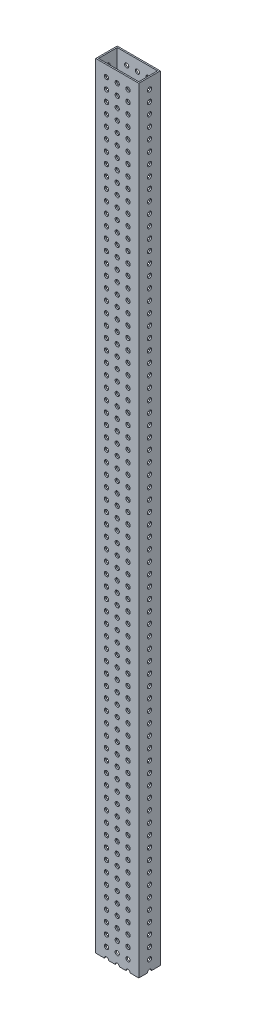
from build123d import *

# Parameters (mm, degrees)
SKETCH1_W           = 50.8
SKETCH1_H           = 25.4
SKETCH1_W_2         = 47.625
SKETCH1_H_2         = 22.225
BOSS_EXTRUDE1_DEPTH = 914.4
SKETCH3_R           = 2.4892
CUT_EXTRUDE1_DEPTH  = 51.8
SKETCH4_R           = 2.4892
CUT_EXTRUDE2_DEPTH  = 26.4


with BuildPart() as part:
    # Sketch1 → Boss-Extrude1 (new body)
    with BuildSketch(Plane(origin=(0, 0, 0), x_dir=(1, 0, 0), z_dir=(0, 1, 0))):
        with Locations((25.4, 12.7)):
            Rectangle(SKETCH1_W, SKETCH1_H)
        with Locations((25.4, 12.7)):
            Rectangle(SKETCH1_W_2, SKETCH1_H_2, mode=Mode.SUBTRACT)
    extrude(amount=BOSS_EXTRUDE1_DEPTH)

    # Sketch3 → Cut-Extrude1 (cut, through all)
    with BuildSketch(Plane(origin=(50.8, 0, 0), x_dir=(0, 0, -1), z_dir=(1, 0, 0))):
        with Locations((12.7, 901.7)):
            Circle(SKETCH3_R)
        with Locations((12.7, 889)):
            Circle(SKETCH3_R)
        with Locations((12.7, 876.3)):
            Circle(SKETCH3_R)
        with Locations((12.7, 863.6)):
            Circle(SKETCH3_R)
        with Locations((12.7, 850.9)):
            Circle(SKETCH3_R)
        with Locations((12.7, 838.2)):
            Circle(SKETCH3_R)
        with Locations((12.7, 825.5)):
            Circle(SKETCH3_R)
        with Locations((12.7, 812.8)):
            Circle(SKETCH3_R)
        with Locations((12.7, 800.1)):
            Circle(SKETCH3_R)
        with Locations((12.7, 787.4)):
            Circle(SKETCH3_R)
        with Locations((12.7, 774.7)):
            Circle(SKETCH3_R)
        with Locations((12.7, 762)):
            Circle(SKETCH3_R)
        with Locations((12.7, 749.3)):
            Circle(SKETCH3_R)
        with Locations((12.7, 736.6)):
            Circle(SKETCH3_R)
        with Locations((12.7, 723.9)):
            Circle(SKETCH3_R)
        with Locations((12.7, 711.2)):
            Circle(SKETCH3_R)
        with Locations((12.7, 698.5)):
            Circle(SKETCH3_R)
        with Locations((12.7, 685.8)):
            Circle(SKETCH3_R)
        with Locations((12.7, 673.1)):
            Circle(SKETCH3_R)
        with Locations((12.7, 660.4)):
            Circle(SKETCH3_R)
        with Locations((12.7, 647.7)):
            Circle(SKETCH3_R)
        with Locations((12.7, 635)):
            Circle(SKETCH3_R)
        with Locations((12.7, 622.3)):
            Circle(SKETCH3_R)
        with Locations((12.7, 609.6)):
            Circle(SKETCH3_R)
        with Locations((12.7, 596.9)):
            Circle(SKETCH3_R)
        with Locations((12.7, 584.2)):
            Circle(SKETCH3_R)
        with Locations((12.7, 571.5)):
            Circle(SKETCH3_R)
        with Locations((12.7, 558.8)):
            Circle(SKETCH3_R)
        with Locations((12.7, 546.1)):
            Circle(SKETCH3_R)
        with Locations((12.7, 533.4)):
            Circle(SKETCH3_R)
        with Locations((12.7, 520.7)):
            Circle(SKETCH3_R)
        with Locations((12.7, 508)):
            Circle(SKETCH3_R)
        with Locations((12.7, 495.3)):
            Circle(SKETCH3_R)
        with Locations((12.7, 482.6)):
            Circle(SKETCH3_R)
        with Locations((12.7, 469.9)):
            Circle(SKETCH3_R)
        with Locations((12.7, 457.2)):
            Circle(SKETCH3_R)
        with Locations((12.7, 444.5)):
            Circle(SKETCH3_R)
        with Locations((12.7, 431.8)):
            Circle(SKETCH3_R)
        with Locations((12.7, 419.1)):
            Circle(SKETCH3_R)
        with Locations((12.7, 406.4)):
            Circle(SKETCH3_R)
        with Locations((12.7, 393.7)):
            Circle(SKETCH3_R)
        with Locations((12.7, 381)):
            Circle(SKETCH3_R)
        with Locations((12.7, 368.3)):
            Circle(SKETCH3_R)
        with Locations((12.7, 355.6)):
            Circle(SKETCH3_R)
        with Locations((12.7, 342.9)):
            Circle(SKETCH3_R)
        with Locations((12.7, 330.2)):
            Circle(SKETCH3_R)
        with Locations((12.7, 317.5)):
            Circle(SKETCH3_R)
        with Locations((12.7, 304.8)):
            Circle(SKETCH3_R)
        with Locations((12.7, 292.1)):
            Circle(SKETCH3_R)
        with Locations((12.7, 279.4)):
            Circle(SKETCH3_R)
        with Locations((12.7, 266.7)):
            Circle(SKETCH3_R)
        with Locations((12.7, 254)):
            Circle(SKETCH3_R)
        with Locations((12.7, 241.3)):
            Circle(SKETCH3_R)
        with Locations((12.7, 228.6)):
            Circle(SKETCH3_R)
        with Locations((12.7, 215.9)):
            Circle(SKETCH3_R)
        with Locations((12.7, 203.2)):
            Circle(SKETCH3_R)
        with Locations((12.7, 190.5)):
            Circle(SKETCH3_R)
        with Locations((12.7, 177.8)):
            Circle(SKETCH3_R)
        with Locations((12.7, 165.1)):
            Circle(SKETCH3_R)
        with Locations((12.7, 152.4)):
            Circle(SKETCH3_R)
        with Locations((12.7, 139.7)):
            Circle(SKETCH3_R)
        with Locations((12.7, 127)):
            Circle(SKETCH3_R)
        with Locations((12.7, 114.3)):
            Circle(SKETCH3_R)
        with Locations((12.7, 101.6)):
            Circle(SKETCH3_R)
        with Locations((12.7, 88.9)):
            Circle(SKETCH3_R)
        with Locations((12.7, 76.2)):
            Circle(SKETCH3_R)
        with Locations((12.7, 63.5)):
            Circle(SKETCH3_R)
        with Locations((12.7, 50.8)):
            Circle(SKETCH3_R)
        with Locations((12.7, 38.1)):
            Circle(SKETCH3_R)
        with Locations((12.7, 25.4)):
            Circle(SKETCH3_R)
        with Locations((12.7, 12.7)):
            Circle(SKETCH3_R)
        with Locations((12.7, 0)):
            Circle(SKETCH3_R)
    extrude(amount=-CUT_EXTRUDE1_DEPTH, mode=Mode.SUBTRACT)

    # Sketch4 → Cut-Extrude2 (cut, through all)
    with BuildSketch(Plane.XY):
        with Locations((12.7, 901.7)):
            Circle(SKETCH4_R)
        with Locations((25.4, 901.7)):
            Circle(SKETCH4_R)
        with Locations((38.1, 901.7)):
            Circle(SKETCH4_R)
        with Locations((25.4, 889)):
            Circle(SKETCH4_R)
        with Locations((38.1, 889)):
            Circle(SKETCH4_R)
        with Locations((25.4, 876.3)):
            Circle(SKETCH4_R)
        with Locations((38.1, 876.3)):
            Circle(SKETCH4_R)
        with Locations((25.4, 863.6)):
            Circle(SKETCH4_R)
        with Locations((38.1, 863.6)):
            Circle(SKETCH4_R)
        with Locations((25.4, 850.9)):
            Circle(SKETCH4_R)
        with Locations((38.1, 850.9)):
            Circle(SKETCH4_R)
        with Locations((25.4, 838.2)):
            Circle(SKETCH4_R)
        with Locations((38.1, 838.2)):
            Circle(SKETCH4_R)
        with Locations((25.4, 825.5)):
            Circle(SKETCH4_R)
        with Locations((38.1, 825.5)):
            Circle(SKETCH4_R)
        with Locations((25.4, 812.8)):
            Circle(SKETCH4_R)
        with Locations((38.1, 812.8)):
            Circle(SKETCH4_R)
        with Locations((25.4, 800.1)):
            Circle(SKETCH4_R)
        with Locations((38.1, 800.1)):
            Circle(SKETCH4_R)
        with Locations((25.4, 787.4)):
            Circle(SKETCH4_R)
        with Locations((38.1, 787.4)):
            Circle(SKETCH4_R)
        with Locations((25.4, 774.7)):
            Circle(SKETCH4_R)
        with Locations((38.1, 774.7)):
            Circle(SKETCH4_R)
        with Locations((25.4, 762)):
            Circle(SKETCH4_R)
        with Locations((38.1, 762)):
            Circle(SKETCH4_R)
        with Locations((25.4, 749.3)):
            Circle(SKETCH4_R)
        with Locations((38.1, 749.3)):
            Circle(SKETCH4_R)
        with Locations((25.4, 736.6)):
            Circle(SKETCH4_R)
        with Locations((38.1, 736.6)):
            Circle(SKETCH4_R)
        with Locations((25.4, 723.9)):
            Circle(SKETCH4_R)
        with Locations((38.1, 723.9)):
            Circle(SKETCH4_R)
        with Locations((25.4, 711.2)):
            Circle(SKETCH4_R)
        with Locations((38.1, 711.2)):
            Circle(SKETCH4_R)
        with Locations((25.4, 698.5)):
            Circle(SKETCH4_R)
        with Locations((38.1, 698.5)):
            Circle(SKETCH4_R)
        with Locations((25.4, 685.8)):
            Circle(SKETCH4_R)
        with Locations((38.1, 685.8)):
            Circle(SKETCH4_R)
        with Locations((25.4, 673.1)):
            Circle(SKETCH4_R)
        with Locations((38.1, 673.1)):
            Circle(SKETCH4_R)
        with Locations((25.4, 660.4)):
            Circle(SKETCH4_R)
        with Locations((38.1, 660.4)):
            Circle(SKETCH4_R)
        with Locations((25.4, 647.7)):
            Circle(SKETCH4_R)
        with Locations((38.1, 647.7)):
            Circle(SKETCH4_R)
        with Locations((25.4, 635)):
            Circle(SKETCH4_R)
        with Locations((38.1, 635)):
            Circle(SKETCH4_R)
        with Locations((25.4, 622.3)):
            Circle(SKETCH4_R)
        with Locations((38.1, 622.3)):
            Circle(SKETCH4_R)
        with Locations((25.4, 609.6)):
            Circle(SKETCH4_R)
        with Locations((38.1, 609.6)):
            Circle(SKETCH4_R)
        with Locations((25.4, 596.9)):
            Circle(SKETCH4_R)
        with Locations((38.1, 596.9)):
            Circle(SKETCH4_R)
        with Locations((25.4, 584.2)):
            Circle(SKETCH4_R)
        with Locations((38.1, 584.2)):
            Circle(SKETCH4_R)
        with Locations((25.4, 571.5)):
            Circle(SKETCH4_R)
        with Locations((38.1, 571.5)):
            Circle(SKETCH4_R)
        with Locations((25.4, 558.8)):
            Circle(SKETCH4_R)
        with Locations((38.1, 558.8)):
            Circle(SKETCH4_R)
        with Locations((25.4, 546.1)):
            Circle(SKETCH4_R)
        with Locations((38.1, 546.1)):
            Circle(SKETCH4_R)
        with Locations((25.4, 533.4)):
            Circle(SKETCH4_R)
        with Locations((38.1, 533.4)):
            Circle(SKETCH4_R)
        with Locations((25.4, 520.7)):
            Circle(SKETCH4_R)
        with Locations((38.1, 520.7)):
            Circle(SKETCH4_R)
        with Locations((25.4, 508)):
            Circle(SKETCH4_R)
        with Locations((38.1, 508)):
            Circle(SKETCH4_R)
        with Locations((25.4, 495.3)):
            Circle(SKETCH4_R)
        with Locations((38.1, 495.3)):
            Circle(SKETCH4_R)
        with Locations((25.4, 482.6)):
            Circle(SKETCH4_R)
        with Locations((38.1, 482.6)):
            Circle(SKETCH4_R)
        with Locations((25.4, 469.9)):
            Circle(SKETCH4_R)
        with Locations((38.1, 469.9)):
            Circle(SKETCH4_R)
        with Locations((25.4, 457.2)):
            Circle(SKETCH4_R)
        with Locations((38.1, 457.2)):
            Circle(SKETCH4_R)
        with Locations((25.4, 444.5)):
            Circle(SKETCH4_R)
        with Locations((38.1, 444.5)):
            Circle(SKETCH4_R)
        with Locations((25.4, 431.8)):
            Circle(SKETCH4_R)
        with Locations((38.1, 431.8)):
            Circle(SKETCH4_R)
        with Locations((25.4, 419.1)):
            Circle(SKETCH4_R)
        with Locations((38.1, 419.1)):
            Circle(SKETCH4_R)
        with Locations((25.4, 406.4)):
            Circle(SKETCH4_R)
        with Locations((38.1, 406.4)):
            Circle(SKETCH4_R)
        with Locations((25.4, 393.7)):
            Circle(SKETCH4_R)
        with Locations((38.1, 393.7)):
            Circle(SKETCH4_R)
        with Locations((25.4, 381)):
            Circle(SKETCH4_R)
        with Locations((38.1, 381)):
            Circle(SKETCH4_R)
        with Locations((25.4, 368.3)):
            Circle(SKETCH4_R)
        with Locations((38.1, 368.3)):
            Circle(SKETCH4_R)
        with Locations((25.4, 355.6)):
            Circle(SKETCH4_R)
        with Locations((38.1, 355.6)):
            Circle(SKETCH4_R)
        with Locations((25.4, 342.9)):
            Circle(SKETCH4_R)
        with Locations((38.1, 342.9)):
            Circle(SKETCH4_R)
        with Locations((25.4, 330.2)):
            Circle(SKETCH4_R)
        with Locations((38.1, 330.2)):
            Circle(SKETCH4_R)
        with Locations((25.4, 317.5)):
            Circle(SKETCH4_R)
        with Locations((38.1, 317.5)):
            Circle(SKETCH4_R)
        with Locations((25.4, 304.8)):
            Circle(SKETCH4_R)
        with Locations((38.1, 304.8)):
            Circle(SKETCH4_R)
        with Locations((25.4, 292.1)):
            Circle(SKETCH4_R)
        with Locations((38.1, 292.1)):
            Circle(SKETCH4_R)
        with Locations((25.4, 279.4)):
            Circle(SKETCH4_R)
        with Locations((38.1, 279.4)):
            Circle(SKETCH4_R)
        with Locations((25.4, 266.7)):
            Circle(SKETCH4_R)
        with Locations((38.1, 266.7)):
            Circle(SKETCH4_R)
        with Locations((25.4, 254)):
            Circle(SKETCH4_R)
        with Locations((38.1, 254)):
            Circle(SKETCH4_R)
        with Locations((25.4, 241.3)):
            Circle(SKETCH4_R)
        with Locations((38.1, 241.3)):
            Circle(SKETCH4_R)
        with Locations((25.4, 228.6)):
            Circle(SKETCH4_R)
        with Locations((38.1, 228.6)):
            Circle(SKETCH4_R)
        with Locations((25.4, 215.9)):
            Circle(SKETCH4_R)
        with Locations((38.1, 215.9)):
            Circle(SKETCH4_R)
        with Locations((25.4, 203.2)):
            Circle(SKETCH4_R)
        with Locations((38.1, 203.2)):
            Circle(SKETCH4_R)
        with Locations((25.4, 190.5)):
            Circle(SKETCH4_R)
        with Locations((38.1, 190.5)):
            Circle(SKETCH4_R)
        with Locations((25.4, 177.8)):
            Circle(SKETCH4_R)
        with Locations((38.1, 177.8)):
            Circle(SKETCH4_R)
        with Locations((25.4, 165.1)):
            Circle(SKETCH4_R)
        with Locations((38.1, 165.1)):
            Circle(SKETCH4_R)
        with Locations((25.4, 152.4)):
            Circle(SKETCH4_R)
        with Locations((38.1, 152.4)):
            Circle(SKETCH4_R)
        with Locations((25.4, 139.7)):
            Circle(SKETCH4_R)
        with Locations((38.1, 139.7)):
            Circle(SKETCH4_R)
        with Locations((25.4, 127)):
            Circle(SKETCH4_R)
        with Locations((38.1, 127)):
            Circle(SKETCH4_R)
        with Locations((25.4, 114.3)):
            Circle(SKETCH4_R)
        with Locations((38.1, 114.3)):
            Circle(SKETCH4_R)
        with Locations((25.4, 101.6)):
            Circle(SKETCH4_R)
        with Locations((38.1, 101.6)):
            Circle(SKETCH4_R)
        with Locations((25.4, 88.9)):
            Circle(SKETCH4_R)
        with Locations((38.1, 88.9)):
            Circle(SKETCH4_R)
        with Locations((25.4, 76.2)):
            Circle(SKETCH4_R)
        with Locations((38.1, 76.2)):
            Circle(SKETCH4_R)
        with Locations((25.4, 63.5)):
            Circle(SKETCH4_R)
        with Locations((38.1, 63.5)):
            Circle(SKETCH4_R)
        with Locations((25.4, 50.8)):
            Circle(SKETCH4_R)
        with Locations((38.1, 50.8)):
            Circle(SKETCH4_R)
        with Locations((25.4, 38.1)):
            Circle(SKETCH4_R)
        with Locations((38.1, 38.1)):
            Circle(SKETCH4_R)
        with Locations((25.4, 25.4)):
            Circle(SKETCH4_R)
        with Locations((38.1, 25.4)):
            Circle(SKETCH4_R)
        with Locations((25.4, 12.7)):
            Circle(SKETCH4_R)
        with Locations((38.1, 12.7)):
            Circle(SKETCH4_R)
        with Locations((25.4, 0)):
            Circle(SKETCH4_R)
        with Locations((38.1, 0)):
            Circle(SKETCH4_R)
        with Locations((12.7, 889)):
            Circle(SKETCH4_R)
        with Locations((12.7, 876.3)):
            Circle(SKETCH4_R)
        with Locations((12.7, 863.6)):
            Circle(SKETCH4_R)
        with Locations((12.7, 850.9)):
            Circle(SKETCH4_R)
        with Locations((12.7, 838.2)):
            Circle(SKETCH4_R)
        with Locations((12.7, 825.5)):
            Circle(SKETCH4_R)
        with Locations((12.7, 812.8)):
            Circle(SKETCH4_R)
        with Locations((12.7, 800.1)):
            Circle(SKETCH4_R)
        with Locations((12.7, 787.4)):
            Circle(SKETCH4_R)
        with Locations((12.7, 774.7)):
            Circle(SKETCH4_R)
        with Locations((12.7, 762)):
            Circle(SKETCH4_R)
        with Locations((12.7, 749.3)):
            Circle(SKETCH4_R)
        with Locations((12.7, 736.6)):
            Circle(SKETCH4_R)
        with Locations((12.7, 723.9)):
            Circle(SKETCH4_R)
        with Locations((12.7, 711.2)):
            Circle(SKETCH4_R)
        with Locations((12.7, 698.5)):
            Circle(SKETCH4_R)
        with Locations((12.7, 685.8)):
            Circle(SKETCH4_R)
        with Locations((12.7, 673.1)):
            Circle(SKETCH4_R)
        with Locations((12.7, 660.4)):
            Circle(SKETCH4_R)
        with Locations((12.7, 647.7)):
            Circle(SKETCH4_R)
        with Locations((12.7, 635)):
            Circle(SKETCH4_R)
        with Locations((12.7, 622.3)):
            Circle(SKETCH4_R)
        with Locations((12.7, 609.6)):
            Circle(SKETCH4_R)
        with Locations((12.7, 596.9)):
            Circle(SKETCH4_R)
        with Locations((12.7, 584.2)):
            Circle(SKETCH4_R)
        with Locations((12.7, 571.5)):
            Circle(SKETCH4_R)
        with Locations((12.7, 558.8)):
            Circle(SKETCH4_R)
        with Locations((12.7, 546.1)):
            Circle(SKETCH4_R)
        with Locations((12.7, 533.4)):
            Circle(SKETCH4_R)
        with Locations((12.7, 520.7)):
            Circle(SKETCH4_R)
        with Locations((12.7, 508)):
            Circle(SKETCH4_R)
        with Locations((12.7, 495.3)):
            Circle(SKETCH4_R)
        with Locations((12.7, 482.6)):
            Circle(SKETCH4_R)
        with Locations((12.7, 469.9)):
            Circle(SKETCH4_R)
        with Locations((12.7, 457.2)):
            Circle(SKETCH4_R)
        with Locations((12.7, 444.5)):
            Circle(SKETCH4_R)
        with Locations((12.7, 431.8)):
            Circle(SKETCH4_R)
        with Locations((12.7, 419.1)):
            Circle(SKETCH4_R)
        with Locations((12.7, 406.4)):
            Circle(SKETCH4_R)
        with Locations((12.7, 393.7)):
            Circle(SKETCH4_R)
        with Locations((12.7, 381)):
            Circle(SKETCH4_R)
        with Locations((12.7, 368.3)):
            Circle(SKETCH4_R)
        with Locations((12.7, 355.6)):
            Circle(SKETCH4_R)
        with Locations((12.7, 342.9)):
            Circle(SKETCH4_R)
        with Locations((12.7, 330.2)):
            Circle(SKETCH4_R)
        with Locations((12.7, 317.5)):
            Circle(SKETCH4_R)
        with Locations((12.7, 304.8)):
            Circle(SKETCH4_R)
        with Locations((12.7, 292.1)):
            Circle(SKETCH4_R)
        with Locations((12.7, 279.4)):
            Circle(SKETCH4_R)
        with Locations((12.7, 266.7)):
            Circle(SKETCH4_R)
        with Locations((12.7, 254)):
            Circle(SKETCH4_R)
        with Locations((12.7, 241.3)):
            Circle(SKETCH4_R)
        with Locations((12.7, 228.6)):
            Circle(SKETCH4_R)
        with Locations((12.7, 215.9)):
            Circle(SKETCH4_R)
        with Locations((12.7, 203.2)):
            Circle(SKETCH4_R)
        with Locations((12.7, 190.5)):
            Circle(SKETCH4_R)
        with Locations((12.7, 177.8)):
            Circle(SKETCH4_R)
        with Locations((12.7, 165.1)):
            Circle(SKETCH4_R)
        with Locations((12.7, 152.4)):
            Circle(SKETCH4_R)
        with Locations((12.7, 139.7)):
            Circle(SKETCH4_R)
        with Locations((12.7, 127)):
            Circle(SKETCH4_R)
        with Locations((12.7, 114.3)):
            Circle(SKETCH4_R)
        with Locations((12.7, 101.6)):
            Circle(SKETCH4_R)
        with Locations((12.7, 88.9)):
            Circle(SKETCH4_R)
        with Locations((12.7, 76.2)):
            Circle(SKETCH4_R)
        with Locations((12.7, 63.5)):
            Circle(SKETCH4_R)
        with Locations((12.7, 50.8)):
            Circle(SKETCH4_R)
        with Locations((12.7, 38.1)):
            Circle(SKETCH4_R)
        with Locations((12.7, 25.4)):
            Circle(SKETCH4_R)
        with Locations((12.7, 12.7)):
            Circle(SKETCH4_R)
        with Locations((12.7, 0)):
            Circle(SKETCH4_R)
    extrude(amount=-CUT_EXTRUDE2_DEPTH, mode=Mode.SUBTRACT)


solid = part.part
